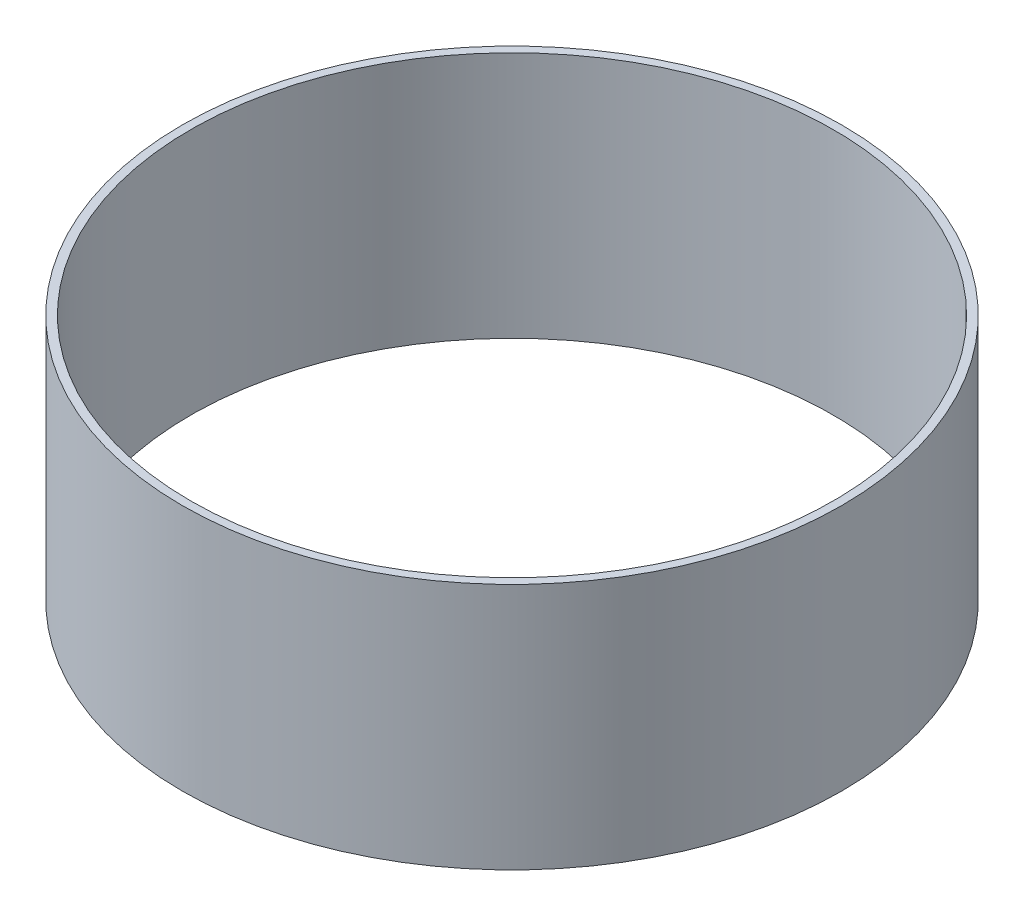
from build123d import *

# Parameters (mm, degrees)
SKETCH1_R           = 400
SKETCH1_R_2         = 390
BOSS_EXTRUDE1_DEPTH = 300


with BuildPart() as part:
    # Sketch1 → Boss-Extrude1 (new body)
    with BuildSketch(Plane(origin=(0, 0, 0), x_dir=(1, 0, 0), z_dir=(0, 1, 0))):
        Circle(SKETCH1_R)
        Circle(SKETCH1_R_2, mode=Mode.SUBTRACT)
    extrude(amount=BOSS_EXTRUDE1_DEPTH)


solid = part.part
